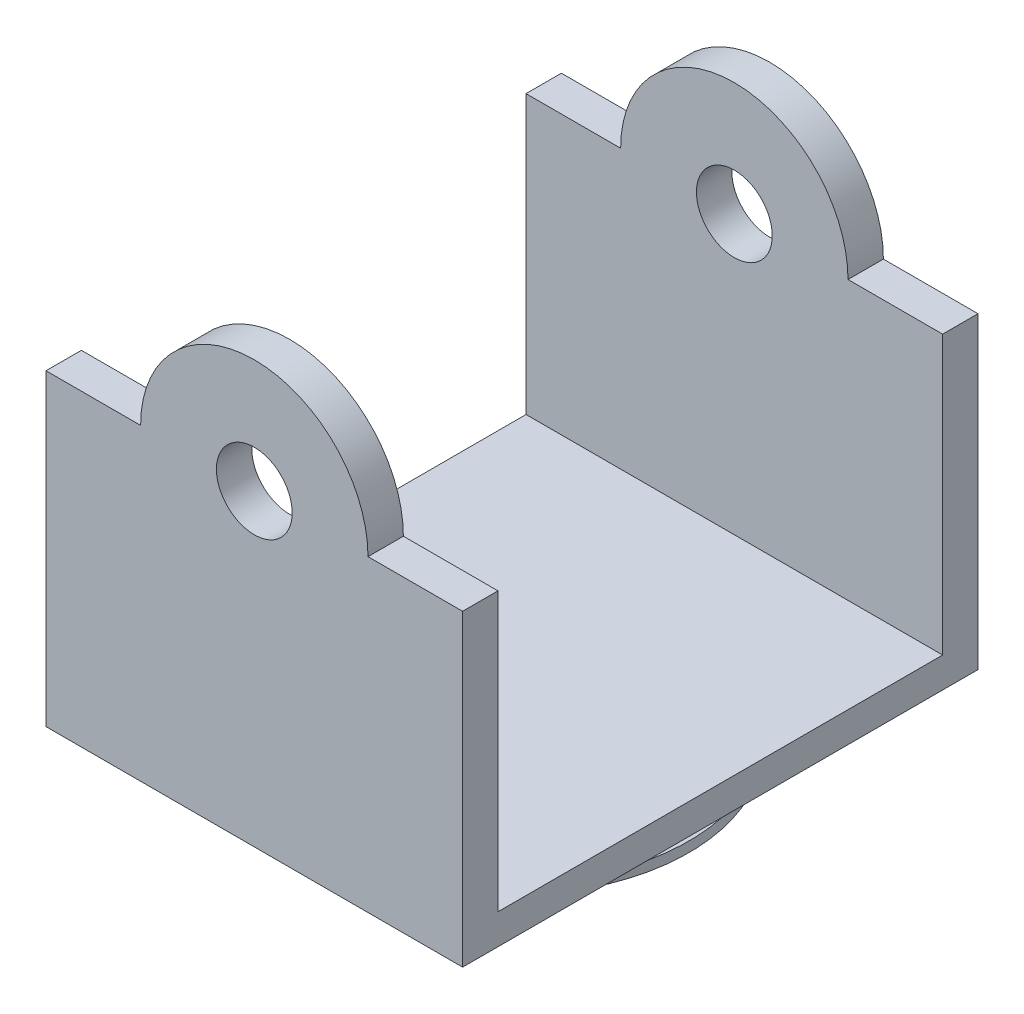
from build123d import *

# Parameters (mm, degrees)
SKETCH1_W             = 82.45
SKETCH1_H             = 88
BOSS_EXTRUDE1_DEPTH   = 6
SKETCH2_W             = 82.45
SKETCH2_H             = 7
BOSS_EXTRUDE2_DEPTH   = 55
BOSS_EXTRUDE2_2_DEPTH = 55
SKETCH2_2_W           = 82.45
SKETCH2_2_H           = 7
BOSS_EXTRUDE3_DEPTH   = 6
SKETCH2_3_W           = 82.45
SKETCH2_3_H           = 7
BOSS_EXTRUDE4_DEPTH   = 6
BOSS_EXTRUDE5_DEPTH   = 7
BOSS_EXTRUDE7_DEPTH   = 7
SKETCH8_R             = 32.5
BOSS_EXTRUDE8_DEPTH   = 7
SKETCH9_R             = 35
BOSS_EXTRUDE9_DEPTH   = 2
SKETCH10_R            = 7.5
CUT_EXTRUDE3_DEPTH    = 7
SKETCH11_R            = 7.5
CUT_EXTRUDE4_DEPTH    = 7


with BuildPart() as part:
    # Sketch1 → Boss-Extrude1 (new body)
    with BuildSketch(Plane(origin=(0, 0, 0), x_dir=(1, 0, 0), z_dir=(0, 1, 0))):
        Rectangle(SKETCH1_W, SKETCH1_H)
    extrude(amount=-BOSS_EXTRUDE1_DEPTH)



with BuildPart() as body_2:
    # Sketch2 → Boss-Extrude2 (new body)
    with BuildSketch(Plane(origin=(0, 0, 0), x_dir=(1, 0, 0), z_dir=(0, 1, 0))):
        with Locations((0, 47.5)):
            Rectangle(SKETCH2_W, SKETCH2_H)
    extrude(amount=BOSS_EXTRUDE2_DEPTH)


with BuildPart() as body_3:
    # Sketch2 → Boss-Extrude2 2 (new body)
    with BuildSketch(Plane(origin=(0, 0, 0), x_dir=(1, 0, 0), z_dir=(0, 1, 0))):
        with Locations((0, -47.5)):
            Rectangle(SKETCH2_W, SKETCH2_H)
    extrude(amount=BOSS_EXTRUDE2_2_DEPTH)


with BuildPart() as part_1:
    add(part.part)

    add(body_2.part)  # Boss-Extrude3 merges body 2
    # Sketch2_2 → Boss-Extrude3 (add)
    with BuildSketch(Plane(origin=(0, 0, 0), x_dir=(1, 0, 0), z_dir=(0, 1, 0))):
        with Locations((0, 47.5)):
            Rectangle(SKETCH2_2_W, SKETCH2_2_H)
    extrude(amount=-BOSS_EXTRUDE3_DEPTH)


    add(body_3.part)  # Boss-Extrude4 merges body 3
    # Sketch2_3 → Boss-Extrude4 (add)
    with BuildSketch(Plane(origin=(0, 0, 0), x_dir=(1, 0, 0), z_dir=(0, 1, 0))):
        with Locations((0, -47.5)):
            Rectangle(SKETCH2_3_W, SKETCH2_3_H)
    extrude(amount=-BOSS_EXTRUDE4_DEPTH)

    # Sketch4 → Boss-Extrude5 (add)
    with BuildSketch(Plane.XY.offset(-44)):
        with BuildLine():
            Line((22.5, 55), (-22.5, 55))
            ThreePointArc((-22.5, 55), (0, 77.5), (22.5, 55))
        make_face()
    extrude(amount=-BOSS_EXTRUDE5_DEPTH)

    # Sketch5 → Boss-Extrude7 (add)
    with BuildSketch(Plane(origin=(0, 0, 44), x_dir=(-1, 0, 0), z_dir=(0, 0, -1))):
        with BuildLine():
            Line((22.5, 55), (-22.5, 55))
            ThreePointArc((-22.5, 55), (0, 77.5), (22.5, 55))
        make_face()
    extrude(amount=-BOSS_EXTRUDE7_DEPTH)

    # Sketch8 → Boss-Extrude8 (add)
    with BuildSketch(Plane.XZ.offset(6)):
        Circle(SKETCH8_R)
    extrude(amount=BOSS_EXTRUDE8_DEPTH)

    # Sketch9 → Boss-Extrude9 (add)
    with BuildSketch(Plane.XZ.offset(13)):
        Circle(SKETCH9_R)
    extrude(amount=BOSS_EXTRUDE9_DEPTH)

    # Sketch10 → Cut-Extrude3 (cut)
    with BuildSketch(Plane.XY.offset(-44)):
        with Locations((0, 55)):
            Circle(SKETCH10_R)
    extrude(amount=-CUT_EXTRUDE3_DEPTH, mode=Mode.SUBTRACT)

    # Sketch11 → Cut-Extrude4 (cut)
    with BuildSketch(Plane(origin=(0, 0, 44), x_dir=(-1, 0, 0), z_dir=(0, 0, -1))):
        with Locations((0, 55)):
            Circle(SKETCH11_R)
    extrude(amount=-CUT_EXTRUDE4_DEPTH, mode=Mode.SUBTRACT)


solid = part_1.part
